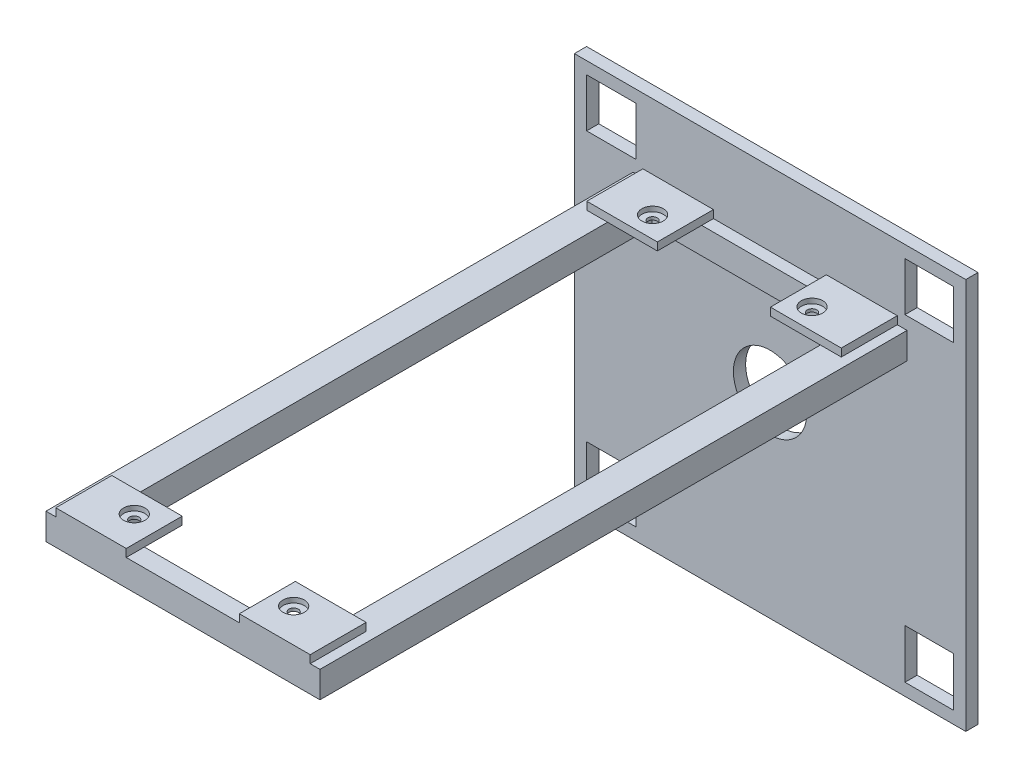
from build123d import *

# Parameters (mm, degrees)
SKETCH1_W                                           = 101.6
SKETCH1_H                                           = 101.6
BOSS_EXTRUDE1_DEPTH                                 = 3.175
SKETCH19_W                                          = 12.75921203
SKETCH19_H                                          = 12.60998148
SKETCH19_W_2                                        = 12.60998148
SKETCH19_H_2                                        = 12.75921203
CUT_EXTRUDE1_DEPTH                                  = 3.175
F_3_4_0_75_DIAMETER_HOLE1_D                         = 19.05
SKETCH29_W                                          = 71.12
SKETCH29_H                                          = 6.858
BOSS_EXTRUDE11_DEPTH                                = 3.048
SKETCH30_W                                          = 7.950155684
SKETCH30_H                                          = 6.858
SKETCH30_W_2                                        = 7.931445158
BOSS_EXTRUDE12_DEPTH                                = 149.352
SKETCH31_W                                          = 4.703535678
SKETCH31_H                                          = 6.858
BOSS_EXTRUDE13_DEPTH                                = 55.88
SKETCH32_W                                          = 18.396349522
SKETCH32_H                                          = 14.53383174
SKETCH32_W_2                                        = 18.288
SKETCH32_H_2                                        = 14.533831847
SKETCH32_W_3                                        = 18.317097516
SKETCH32_H_3                                        = 14.559025954
BOSS_EXTRUDE14_DEPTH                                = 2.032
CBORE_FOR_2_BINDING_HEAD_MACHINE_SCREW1_D           = 2.4384
CBORE_FOR_2_BINDING_HEAD_MACHINE_SCREW1_CBORE_D     = 5.55752
CBORE_FOR_2_BINDING_HEAD_MACHINE_SCREW1_CBORE_DEPTH = 1.27


with BuildPart() as part:
    # Sketch1 → Boss-Extrude1 (new body)
    with BuildSketch(Plane.XY):
        with Locations((52.482861157, 13.097719286)):
            Rectangle(SKETCH1_W, SKETCH1_H)
    extrude(amount=BOSS_EXTRUDE1_DEPTH)

    # Sketch19 → Cut-Extrude1 (cut)
    with BuildSketch(Plane.XY.offset(3.175)):
        with Locations((11.237467172, 54.417728546)):
            Rectangle(SKETCH19_W, SKETCH19_H)
        with Locations((93.802870417, -28.147674699)):
            Rectangle(SKETCH19_W_2, SKETCH19_H_2)
        with Locations((93.802870417, 54.417728546)):
            Rectangle(SKETCH19_W_2, SKETCH19_H)
        with Locations((11.237467172, -28.147674699)):
            Rectangle(SKETCH19_W, SKETCH19_H_2)
    extrude(amount=-CUT_EXTRUDE1_DEPTH, mode=Mode.SUBTRACT)

    # 3/4 (0.75) Diameter Hole1 (through all)
    with Locations(Plane(origin=(0, 0, 0), x_dir=(-1, 0, 0), z_dir=(0, 0, -1))):
        with Locations((-52.482861157, 13.097719286)):
            Hole(F_3_4_0_75_DIAMETER_HOLE1_D / 2)

    # Sketch29 → Boss-Extrude11 (add)
    with BuildSketch(Plane.XY.offset(3.175)):
        with Locations((52.482988157, 41.418719286)):
            Rectangle(SKETCH29_W, SKETCH29_H)
    extrude(amount=BOSS_EXTRUDE11_DEPTH)

    # Sketch30 → Boss-Extrude12 (add)
    with BuildSketch(Plane.XY.offset(6.223)):
        with Locations((84.067910315, 41.418719286)):
            Rectangle(SKETCH30_W, SKETCH30_H)
        with Locations((20.888710736, 41.418719286)):
            Rectangle(SKETCH30_W_2, SKETCH30_H)
    extrude(amount=BOSS_EXTRUDE12_DEPTH)

    # Sketch31 → Boss-Extrude13 (add)
    with BuildSketch(Plane.ZY.offset(-80.092832473)):
        with Locations((153.223232161, 41.418719286)):
            Rectangle(SKETCH31_W, SKETCH31_H)
    extrude(amount=BOSS_EXTRUDE13_DEPTH)

    # Sketch32 → Boss-Extrude14 (add)
    with BuildSketch(Plane(origin=(0, 44.847719286, 0), x_dir=(1, 0, 0), z_dir=(0, 1, 0))):
        with Locations((76.304813396, -148.30808413)):
            Rectangle(SKETCH32_W, SKETCH32_H)
        with Locations((28.606988157, -148.30808413)):
            Rectangle(SKETCH32_W_2, SKETCH32_H)
        with Locations((76.304813396, -10.441915924)):
            Rectangle(SKETCH32_W, SKETCH32_H_2)
        with Locations((28.621536915, -10.454512977)):
            Rectangle(SKETCH32_W_3, SKETCH32_H_3)
    extrude(amount=BOSS_EXTRUDE14_DEPTH)

    # CBORE for #2 Binding Head Machine Screw1 (through all)
    with Locations(Plane(origin=(0, 46.879719286, 0), x_dir=(1, 0, 0), z_dir=(0, 1, 0))):
        with Locations((31.071863114, -12.257454761), (72.45160574, -12.257454761), (72.45160574, -146.811730834), (31.071863114, -146.811730834)):
            CounterBoreHole(CBORE_FOR_2_BINDING_HEAD_MACHINE_SCREW1_D / 2, CBORE_FOR_2_BINDING_HEAD_MACHINE_SCREW1_CBORE_D / 2, CBORE_FOR_2_BINDING_HEAD_MACHINE_SCREW1_CBORE_DEPTH)


solid = part.part
